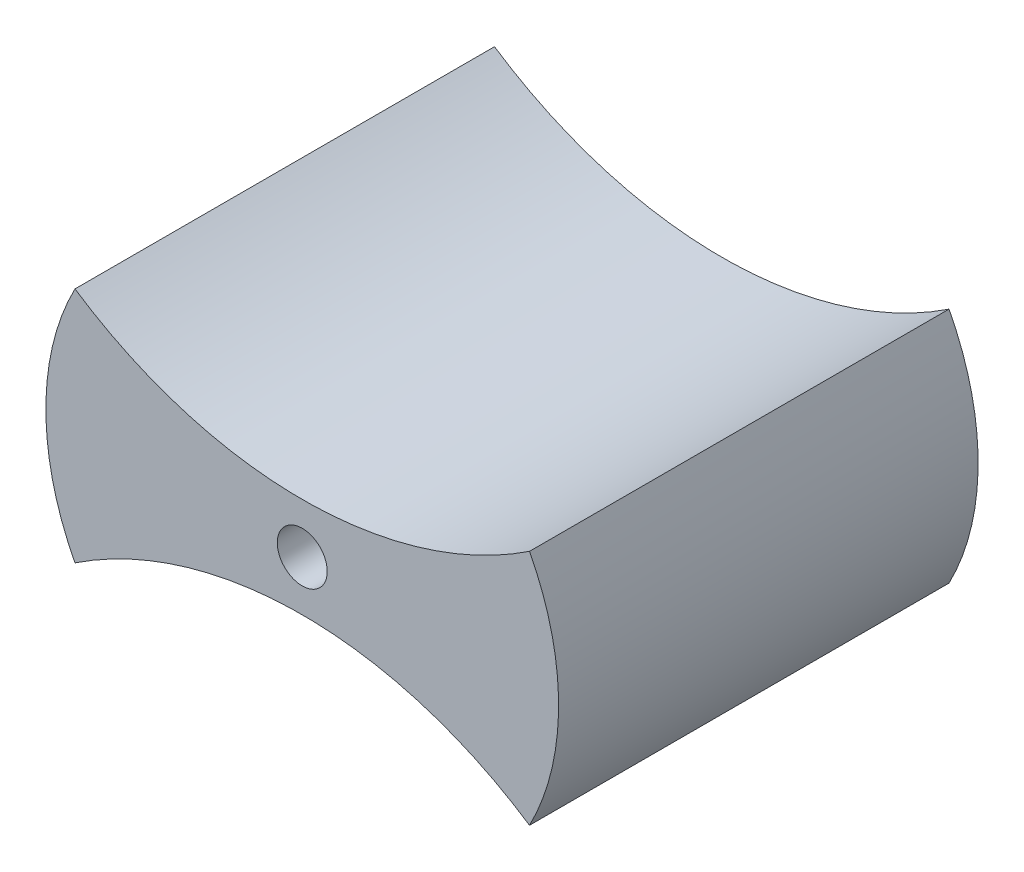
from build123d import *

# Parameters (mm, degrees)
SKETCH_1_R      = 1.5
EXTRUDE_1_DEPTH = 25.2


with BuildPart() as part:
    # 草图1 → 凸台-拉伸1 (new body)
    with BuildSketch(Plane.XY):
        with BuildLine():
            ThreePointArc((-13.651838143, 7.126521965), (-14.525683909, 5.115125313), (-15.104966071, 3))
            Line((-15.104966071, 3), (1.6e-08, 3))
            ThreePointArc((1.6e-08, 3), (-7.130933806, 4.054175866), (-13.651838143, 7.126521965))
        make_face()
        with BuildLine():
            Line((1.6e-08, 3), (-15.104966071, 3))
            ThreePointArc((-15.104966071, 3), (-15.326064033, 1.507236297), (-15.4, 0))
            ThreePointArc((-15.4, 0), (-15.326064033, -1.507236297), (-15.104966071, -3))
            Line((-15.104966071, -3), (0, -3))
            Line((0, -3), (15.104966071, -3))
            ThreePointArc((15.104966071, -3), (15.326064033, -1.507236297), (15.4, 0))
            ThreePointArc((15.4, 0), (15.326064033, 1.507236297), (15.104966071, 3))
            Line((15.104966071, 3), (1.6e-08, 3))
        make_face()
        Circle(SKETCH_1_R, mode=Mode.SUBTRACT)
        with BuildLine():
            Line((0, -3), (-15.104966071, -3))
            ThreePointArc((-15.104966071, -3), (-14.525683909, -5.115125313), (-13.651838143, -7.126521965))
            ThreePointArc((-13.651838143, -7.126521965), (-7.130933814, -4.054175868), (0, -3))
        make_face()
        with BuildLine():
            ThreePointArc((13.651838143, 7.126521965), (7.130933821, 4.05417587), (1.6e-08, 3))
            Line((1.6e-08, 3), (15.104966071, 3))
            ThreePointArc((15.104966071, 3), (14.525683909, 5.115125313), (13.651838143, 7.126521965))
        make_face()
        with BuildLine():
            Line((15.104966071, -3), (0, -3))
            ThreePointArc((0, -3), (7.130933814, -4.054175868), (13.651838143, -7.126521965))
            ThreePointArc((13.651838143, -7.126521965), (14.525683909, -5.115125313), (15.104966071, -3))
        make_face()
    extrude(amount=EXTRUDE_1_DEPTH)


solid = part.part
